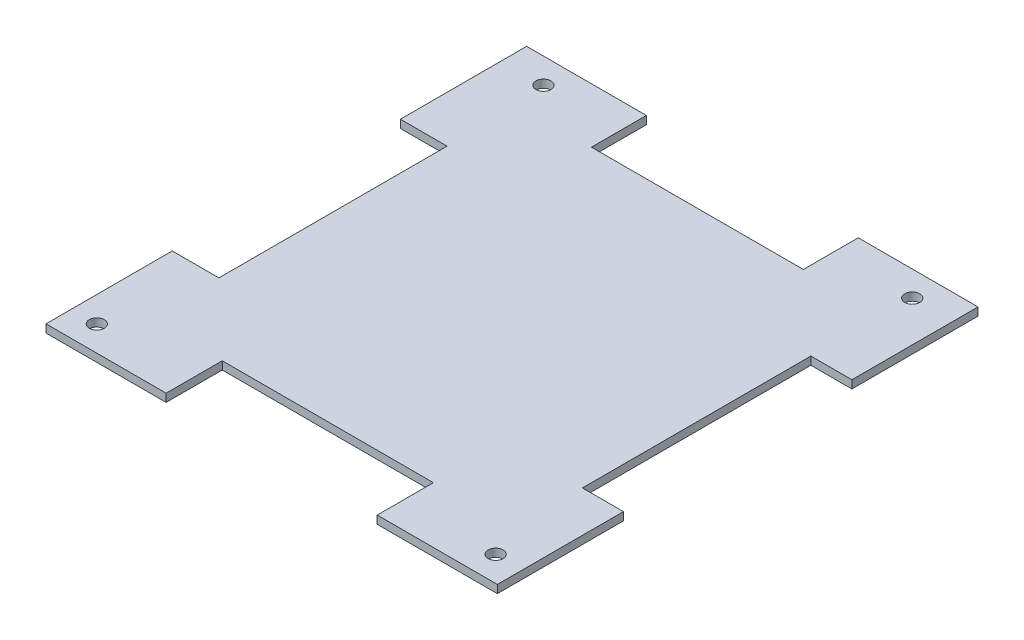
from build123d import *

# Parameters (mm, degrees)
SKETCH2_W           = 84.57
SKETCH2_H           = 90.8
BOSS_EXTRUDE1_DEPTH = 1.6
SKETCH3_R           = 1.5
CUT_EXTRUDE1_DEPTH  = 2.6
SKETCH4_W           = 90.8
SKETCH4_H           = 1.6
BOSS_EXTRUDE2_DEPTH = 2.88
SKETCH5_W           = 90.8
SKETCH5_H           = 1.6
BOSS_EXTRUDE3_DEPTH = 2.59
SKETCH6_W           = 90.04
SKETCH6_H           = 1.6
BOSS_EXTRUDE4_DEPTH = 2.54
SKETCH7_W           = 90.04
SKETCH7_H           = 1.6
BOSS_EXTRUDE5_DEPTH = 2.54
SKETCH8_W           = 16.372642976
SKETCH8_H           = 45.571517242
SKETCH8_W_2         = 42.266473234
SKETCH8_H_2         = 21.901065616
SKETCH8_W_3         = 18.617013656
SKETCH8_H_3         = 45.520108402
SKETCH8_W_4         = 42.118702304
SKETCH8_H_4         = 22.400138828
CUT_EXTRUDE2_DEPTH  = 2.6


with BuildPart() as part:
    # Sketch2 → Boss-Extrude1 (new body)
    with BuildSketch(Plane(origin=(0, 0, 0), x_dir=(1, 0, 0), z_dir=(0, 1, 0))):
        with Locations((42.285, 45.4)):
            Rectangle(SKETCH2_W, SKETCH2_H)
    extrude(amount=BOSS_EXTRUDE1_DEPTH)

    # Sketch3 → Cut-Extrude1 (cut, through all)
    with BuildSketch(Plane(origin=(0, 1.6, 0), x_dir=(1, 0, 0), z_dir=(0, 1, 0))):
        with Locations((2.5, 2.5)):
            Circle(SKETCH3_R)
        with Locations((82.07, 2.5)):
            Circle(SKETCH3_R)
        with Locations((5.8, 88.3)):
            Circle(SKETCH3_R)
        with Locations((79.37, 88.3)):
            Circle(SKETCH3_R)
    extrude(amount=-CUT_EXTRUDE1_DEPTH, mode=Mode.SUBTRACT)

    # Sketch4 → Boss-Extrude2 (add)
    with BuildSketch(Plane(origin=(84.57, 0, 0), x_dir=(0, 0, -1), z_dir=(1, 0, 0))):
        with Locations((45.4, 0.8)):
            Rectangle(SKETCH4_W, SKETCH4_H)
    extrude(amount=BOSS_EXTRUDE2_DEPTH)

    # Sketch5 → Boss-Extrude3 (add)
    with BuildSketch(Plane.ZY):
        with Locations((-45.4, 0.8)):
            Rectangle(SKETCH5_W, SKETCH5_H)
    extrude(amount=BOSS_EXTRUDE3_DEPTH)

    # Sketch6 → Boss-Extrude4 (add)
    with BuildSketch(Plane(origin=(0, 0, -90.8), x_dir=(-1, 0, 0), z_dir=(0, 0, -1))):
        with Locations((-42.43, 0.8)):
            Rectangle(SKETCH6_W, SKETCH6_H)
    extrude(amount=BOSS_EXTRUDE4_DEPTH)

    # Sketch7 → Boss-Extrude5 (add)
    with BuildSketch(Plane.XY):
        with Locations((42.43, 0.8)):
            Rectangle(SKETCH7_W, SKETCH7_H)
    extrude(amount=BOSS_EXTRUDE5_DEPTH)

    # Sketch8 → Cut-Extrude2 (cut, through all)
    with BuildSketch(Plane(origin=(0, 1.6, 0), x_dir=(1, 0, 0), z_dir=(0, 1, 0))):
        with Locations((87.45, 45.4)):
            Rectangle(SKETCH8_W, SKETCH8_H)
        with Locations((42.43, 93.34)):
            Rectangle(SKETCH8_W_2, SKETCH8_H_2)
        with Locations((-2.59, 45.4)):
            Rectangle(SKETCH8_W_3, SKETCH8_H_3)
        with Locations((42.43, -2.54)):
            Rectangle(SKETCH8_W_4, SKETCH8_H_4)
    extrude(amount=-CUT_EXTRUDE2_DEPTH, mode=Mode.SUBTRACT)


solid = part.part
